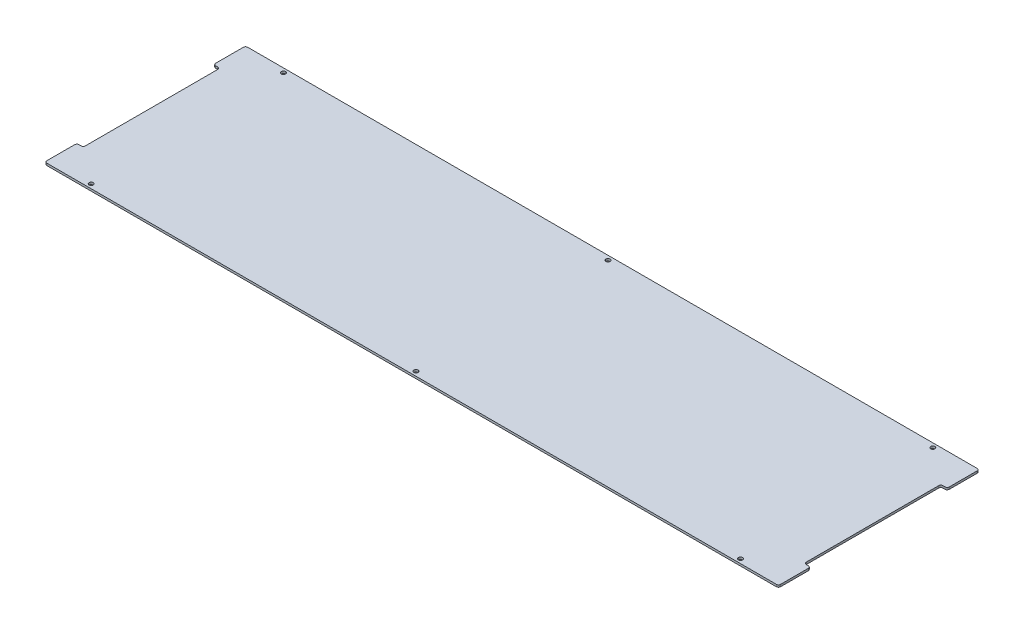
from build123d import *

# Parameters (mm, degrees)
SKETCH1_W                   = 1090.6125
SKETCH1_H                   = 298.45
BOSS_EXTRUDE1_DEPTH         = 3.175
SKETCH2_W                   = 9.525
SKETCH2_H                   = 203.2
CUT_EXTRUDE1_DEPTH          = 4.175
FILLET1_R                   = 3.175
FILLET1_OF_MIRROR1_R        = 3.175
F_1_4_0_25_DIAMETER_HOLE1_D = 6.35
FILLET2_R                   = 3.175


with BuildPart() as part:
    # Sketch1 → Boss-Extrude1 (new body)
    with BuildSketch(Plane(origin=(0, 0, 0), x_dir=(1, 0, 0), z_dir=(0, 1, 0))):
        Rectangle(SKETCH1_W, SKETCH1_H)
    extrude(amount=BOSS_EXTRUDE1_DEPTH)

    # Sketch2 → Cut-Extrude1 (cut, through all)
    with BuildSketch(Plane(origin=(0, 3.175, 0), x_dir=(1, 0, 0), z_dir=(0, 1, 0))):
        with Locations((540.54375, 0)):
            Rectangle(SKETCH2_W, SKETCH2_H)
    cut_extrude1 = extrude(amount=-CUT_EXTRUDE1_DEPTH, mode=Mode.SUBTRACT)

    # Fillet1
    fillet1_edges = [part.edges().sort_by_distance(p)[0] for p in [
        (535.78125, 1.5875, 101.6),
        (535.78125, 1.5875, -101.6),
    ]]
    fillet(fillet1_edges, radius=FILLET1_R)

    # Mirror1: Cut-Extrude1 across plane
    add(cut_extrude1.mirror(Plane(origin=(0, 0, 0), x_dir=(0, 0, 1), z_dir=(1, 0, 0))), mode=Mode.SUBTRACT)

    # Fillet1 of Mirror1
    fillet1_of_mirror1_edges = [part.edges().sort_by_distance(p)[0] for p in [
        (-535.78125, 1.5875, 101.6),
        (-535.78125, 1.5875, -101.6),
    ]]
    fillet(fillet1_of_mirror1_edges, radius=FILLET1_OF_MIRROR1_R)

    # 1/4 (0.25) Diameter Hole1 (through all)
    with Locations(Plane(origin=(0, 3.175, 0), x_dir=(1, 0, 0), z_dir=(0, 1, 0))):
        with Locations((482.6, 142.875), (0, 142.875), (-482.6, 142.875)):
            f_1_4_0_25_diameter_hole1 = Hole(F_1_4_0_25_DIAMETER_HOLE1_D / 2)

    # Mirror2: 1/4 (0.25) Diameter Hole1 across plane
    add(f_1_4_0_25_diameter_hole1.mirror(Plane.XY), mode=Mode.SUBTRACT)

    # Fillet2
    fillet2_edges = [part.edges().sort_by_distance(p)[0] for p in [
        (545.30625, 1.5875, -101.6),
        (545.30625, 1.5875, 101.6),
        (-545.30625, 1.5875, 101.6),
        (-545.30625, 1.5875, -101.6),
        (545.30625, 1.5875, 149.225),
        (-545.30625, 1.5875, 149.225),
        (-545.30625, 1.5875, -149.225),
        (545.30625, 1.5875, -149.225),
    ]]
    fillet(fillet2_edges, radius=FILLET2_R)


solid = part.part
